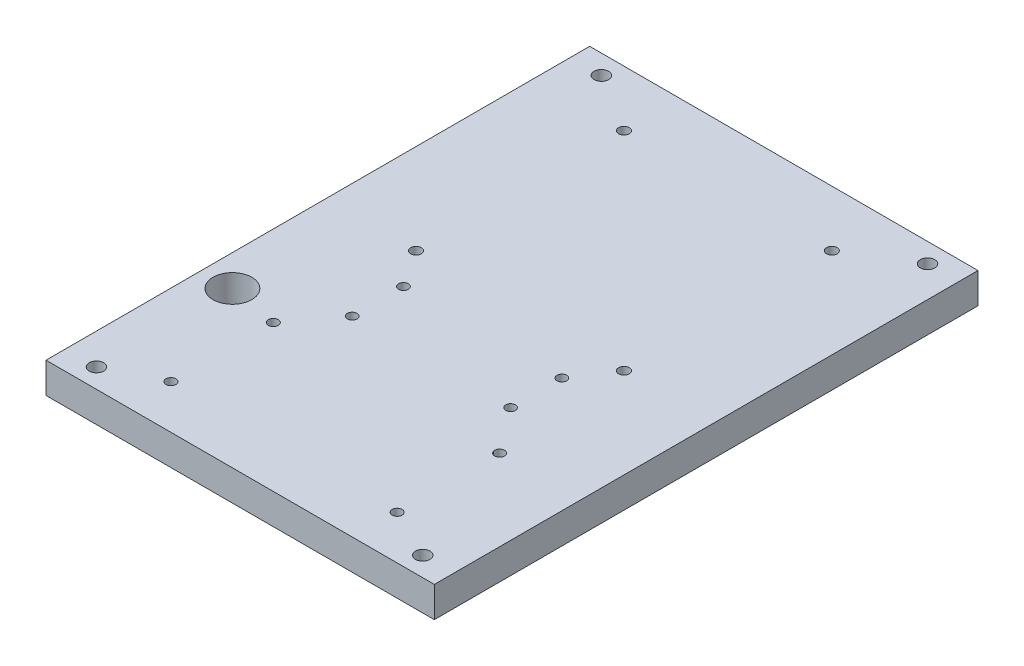
from build123d import *

# Parameters (mm, degrees)
SKETCH1_W           = 127
SKETCH1_H           = 177.8
SKETCH1_R           = 2.3749
SKETCH1_R_2         = 6.35
BOSS_EXTRUDE1_DEPTH = 10
SKETCH8_R           = 1.625
BREADBOARD_DEPTH    = 10
SKETCH9_R           = 1.75
FPGA_DEPTH          = 10
SKETCH10_R          = 1.5875
F_8PUSH_BTN_DEPTH   = 10


with BuildPart() as part:
    # Sketch1 → Boss-Extrude1 (new body)
    with BuildSketch(Plane(origin=(0, 0, 0), x_dir=(1, 0, 0), z_dir=(0, 1, 0))):
        Rectangle(SKETCH1_W, SKETCH1_H)
        with Locations(Location((-53.34, 82.55, 0), (0, 0, 270))):  # turned: the seam where the file's is
            Circle(SKETCH1_R, mode=Mode.SUBTRACT)
        with Locations(Location((53.34, 82.55, 0), (0, 0, 270))):  # turned: the seam where the file's is
            Circle(SKETCH1_R, mode=Mode.SUBTRACT)
        with Locations(Location((53.34, -82.55, 0), (0, 0, 270))):  # turned: the seam where the file's is
            Circle(SKETCH1_R, mode=Mode.SUBTRACT)
        with Locations(Location((-53.34, -82.55, 0), (0, 0, 270))):  # turned: the seam where the file's is
            Circle(SKETCH1_R, mode=Mode.SUBTRACT)
        with Locations(Location((-53.34, -38.1, 0), (0, 0, 270))):  # turned: the seam where the file's is
            Circle(SKETCH1_R_2, mode=Mode.SUBTRACT)
    extrude(amount=BOSS_EXTRUDE1_DEPTH)

    # Sketch8 → Breadboard (cut)
    with BuildSketch(Plane(origin=(0, 10, 0), x_dir=(1, 0, 0), z_dir=(0, 1, 0))):
        with Locations(Location((37, -74.5497835, 0), (0, 0, 270))):  # turned: the seam where the file's is
            Circle(SKETCH8_R)
        with Locations(Location((-37, -74.5497835, 0), (0, 0, 270))):  # turned: the seam where the file's is
            Circle(SKETCH8_R)
        with Locations(Location((-37, -41.0497835, 0), (0, 0, 270))):  # turned: the seam where the file's is
            Circle(SKETCH8_R)
        with Locations(Location((37, -41.0497835, 0), (0, 0, 270))):  # turned: the seam where the file's is
            Circle(SKETCH8_R)
    extrude(amount=-BREADBOARD_DEPTH, mode=Mode.SUBTRACT)

    # Sketch9 → FPGA (cut)
    with BuildSketch(Plane(origin=(0, 10, 0), x_dir=(1, 0, 0), z_dir=(0, 1, 0))):
        with Locations(Location((-34, 70.603714811, 0), (0, 0, 270))):  # turned: the seam where the file's is
            Circle(SKETCH9_R)
        with Locations(Location((34, 70.603714811, 0), (0, 0, 270))):  # turned: the seam where the file's is
            Circle(SKETCH9_R)
        with Locations(Location((34, 2.603714811, 0), (0, 0, 270))):  # turned: the seam where the file's is
            Circle(SKETCH9_R)
        with Locations(Location((-34, 2.603714811, 0), (0, 0, 270))):  # turned: the seam where the file's is
            Circle(SKETCH9_R)
    extrude(amount=-FPGA_DEPTH, mode=Mode.SUBTRACT)

    # Sketch10 → 8Push_btn (cut)
    with BuildSketch(Plane(origin=(0, 10, 0), x_dir=(1, 0, 0), z_dir=(0, 1, 0))):
        with Locations(Location((-25.908, -9.593705545, 0), (0, 0, 270))):  # turned: the seam where the file's is
            Circle(SKETCH10_R)
        with Locations(Location((-25.908, -26.357705545, 0), (0, 0, 270))):  # turned: the seam where the file's is
            Circle(SKETCH10_R)
        with Locations(Location((25.908, -26.357705545, 0), (0, 0, 270))):  # turned: the seam where the file's is
            Circle(SKETCH10_R)
        with Locations(Location((25.908, -9.593705545, 0), (0, 0, 270))):  # turned: the seam where the file's is
            Circle(SKETCH10_R)
    extrude(amount=-F_8PUSH_BTN_DEPTH, mode=Mode.SUBTRACT)


solid = part.part
